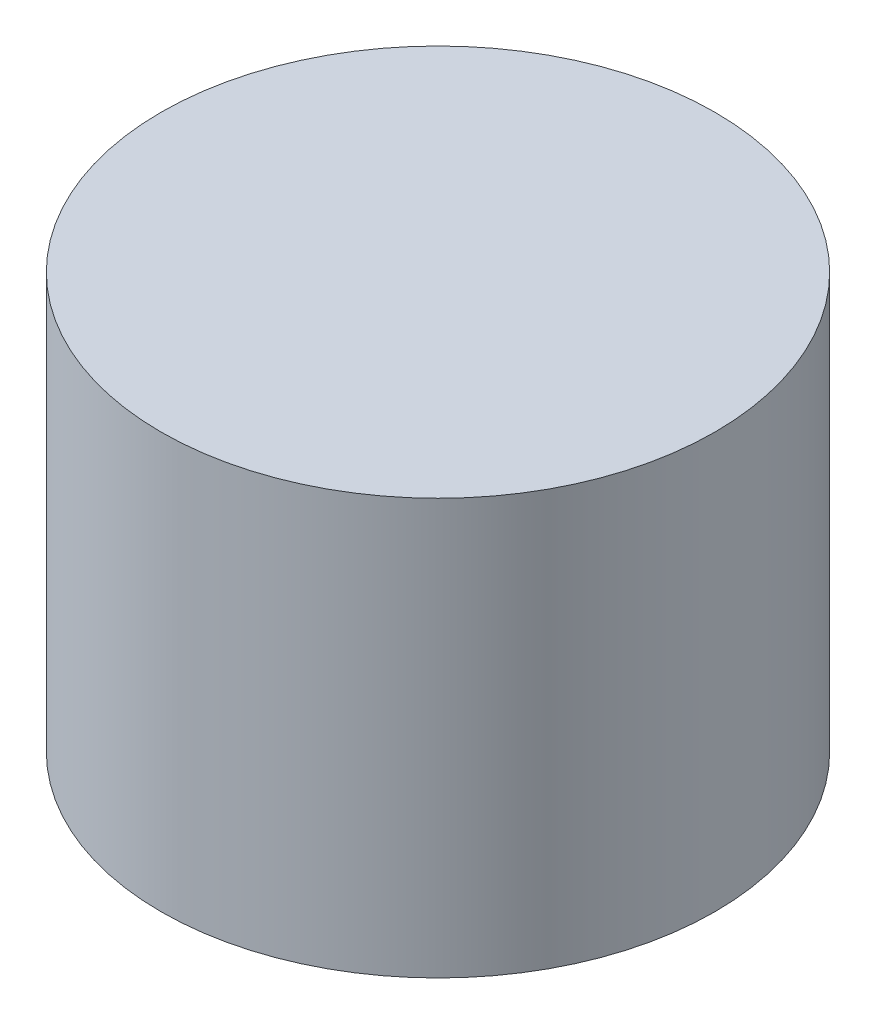
from build123d import *

# Parameters (mm, degrees)
SKETCH_1_R      = 3.5
EXTRUDE_1_DEPTH = 5.25


with BuildPart() as part:
    # ｽｹｯﾁ1 → ﾎﾞｽ - 押し出し1 (new body)
    with BuildSketch(Plane(origin=(0, 0, 0), x_dir=(1, 0, 0), z_dir=(0, 1, 0))):
        Circle(SKETCH_1_R)
    extrude(amount=EXTRUDE_1_DEPTH)


solid = part.part
